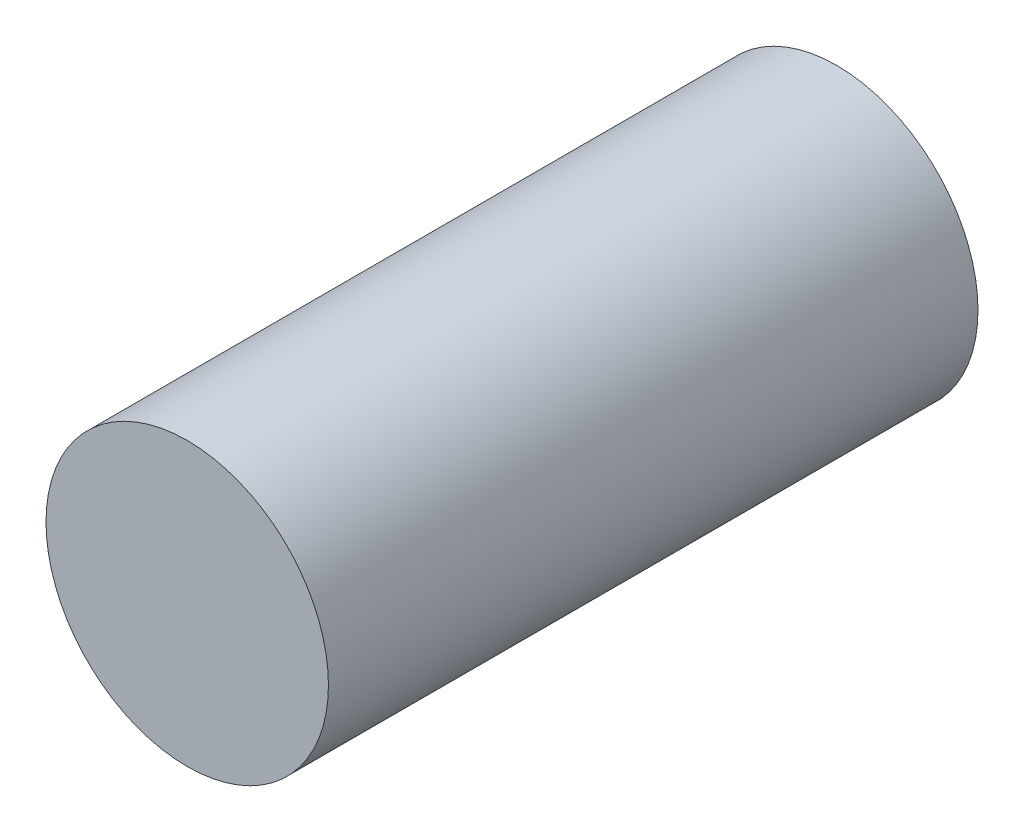
from build123d import *

# Parameters (mm, degrees)
SKETCH1_R           = 1.27
BOSS_EXTRUDE1_DEPTH = 5.842


with BuildPart() as part:
    # Sketch1 → Boss-Extrude1 (new body)
    with BuildSketch(Plane.XY):
        Circle(SKETCH1_R)
    extrude(amount=BOSS_EXTRUDE1_DEPTH)


solid = part.part
